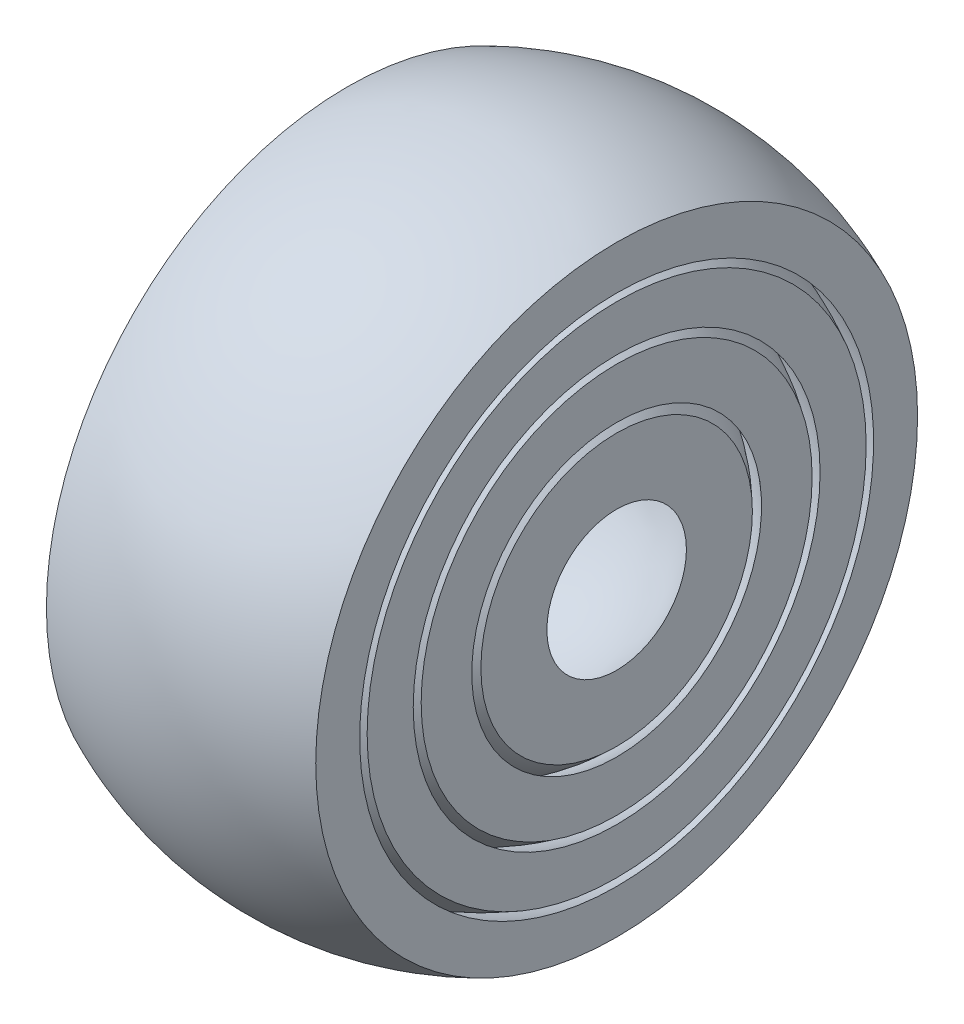
from build123d import *

# Parameters (mm, degrees)
CUT_EXTRUDE5_DEPTH      = 87.602540378
CUT_EXTRUDE5_DEPTH_BACK = 87.602540378
SKETCH4_W               = 43.620255922
SKETCH4_H               = 120.900361544


with BuildPart() as part:
    # Sketch1 → Revolve1 (revolve)
    with BuildSketch(Plane.XY):
        with BuildLine():
            Line((0, 50), (0, 44))
            ThreePointArc((0, 44), (-44, 0), (0, -44))
            Line((0, -44), (0, -50))
            ThreePointArc((0, -50), (-50, 0), (0, 50))
        make_face()
        with BuildLine():
            Line((0, 43), (0, 37))
            ThreePointArc((0, 37), (-37, 0), (0, -37))
            Line((0, -37), (0, -43))
            ThreePointArc((0, -43), (-43, 0), (0, 43))
        make_face()
        with BuildLine():
            Line((0, 36), (0, 30))
            ThreePointArc((0, 30), (-30, 0), (0, -30))
            Line((0, -30), (0, -36))
            ThreePointArc((0, -36), (-36, 0), (0, 36))
        make_face()
        with BuildLine():
            Line((0, 29), (0, 23))
            ThreePointArc((0, 23), (-23, 0), (0, -23))
            Line((0, -23), (0, -29))
            ThreePointArc((0, -29), (-29, 0), (0, 29))
        make_face()
    revolve(axis=Axis((0, 60.113299862, 0), (0, -1, 0)))

    # Sketch4 → Cut-Extrude5 (cut, two sides: drawn at the far end of the back side and taken through both)
    with BuildSketch(Plane.XY.offset(-CUT_EXTRUDE5_DEPTH_BACK)):
        with Locations((-42.232168816, 4.72106675)):
            Rectangle(SKETCH4_W, SKETCH4_H)
        with Locations((42.232168816, 4.72106675)):
            Rectangle(SKETCH4_W, SKETCH4_H)
    extrude(amount=CUT_EXTRUDE5_DEPTH + CUT_EXTRUDE5_DEPTH_BACK, mode=Mode.SUBTRACT)


solid = part.part
